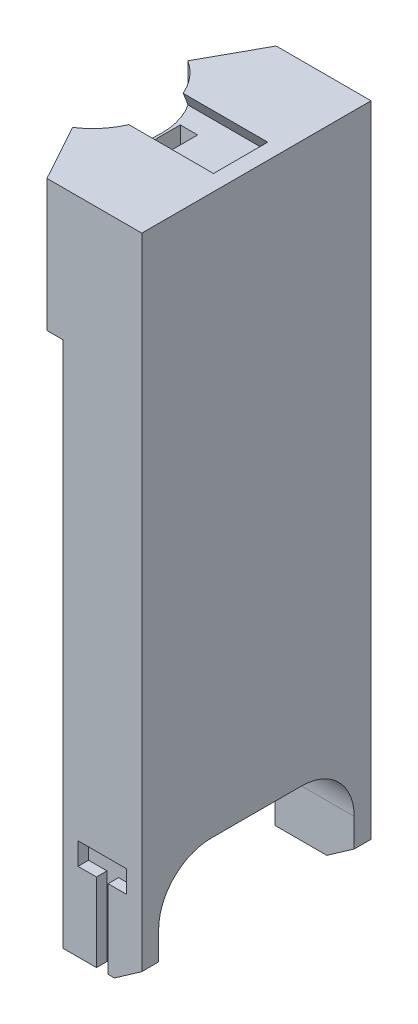
from build123d import *

# Parameters (mm, degrees)
SKETCH2_W               = 18
SKETCH2_H               = 43.5
BOSS_EXTRUDE1_DEPTH     = 25
CUT_EXTRUDE1_DEPTH      = 15
CUT_EXTRUDE1_DEPTH_BACK = 6.951267747
CUT_EXTRUDE2_START      = 0.4
CUT_EXTRUDE2_DEPTH      = 3.3
SKETCH5_W               = 15
SKETCH5_H               = 43.5
BOSS_EXTRUDE2_DEPTH     = 100
SKETCH6_W               = 2.2
SKETCH6_H               = 14.9
CUT_EXTRUDE3_DEPTH      = 2
CUT_EXTRUDE4_START      = -43.5
SKETCH6_3_W             = 2.2
SKETCH6_3_H             = 14.9
CUT_EXTRUDE4_DEPTH      = 2
CUT_EXTRUDE5_DEPTH      = 44.5
SKETCH8_W               = 37.1
SKETCH8_H               = 38
CUT_EXTRUDE6_DEPTH      = 16
FILLET1_R               = 10


with BuildPart() as part:
    # Sketch2 → Boss-Extrude1 (new body)
    with BuildSketch(Plane(origin=(0, 0, 0), x_dir=(1, 0, 0), z_dir=(0, 1, 0))):
        with BuildLine():
            Line((-9, 0), (-9, 21.75))
            Line((-9, 21.75), (-14.951267747, 10.950365309))
            ThreePointArc((-14.951267747, 10.950365309), (-10.583942354, 6.231534486), (-9, 0))
        make_face()
        with BuildLine():
            Line((-9, -21.75), (-9, 0))
            ThreePointArc((-9, 0), (-10.583942354, -6.231534486), (-14.951267747, -10.950365309))
            Line((-14.951267747, -10.950365309), (-9, -21.75))
        make_face()
        Rectangle(SKETCH2_W, SKETCH2_H)
    extrude(amount=BOSS_EXTRUDE1_DEPTH)

    # Sketch3 → Cut-Extrude1 (cut, two sides)
    with BuildSketch(Plane(origin=(-9, 0, 0), x_dir=(0, 0, -1), z_dir=(1, 0, 0))) as cut_extrude1_sk:
        Polygon((-5.15, 25), (5.15, 25), (7.15, 21.535898385), (-7.15, 21.535898385), align=None)
    extrude(amount=CUT_EXTRUDE1_DEPTH, mode=Mode.SUBTRACT)
    extrude(cut_extrude1_sk.sketch, amount=-CUT_EXTRUDE1_DEPTH_BACK, mode=Mode.SUBTRACT)

    # Sketch4 → Cut-Extrude2 (cut)
    with BuildSketch(Plane(origin=(-9, 0, 0), x_dir=(0, 0, -1), z_dir=(1, 0, 0)).offset(CUT_EXTRUDE2_START)):
        with BuildLine():
            Line((3.15, 29.404082691), (3.15, 4.535898385))
            ThreePointArc((3.15, 4.535898385), (0, 1.385898385), (-3.15, 4.535898385))
            Line((-3.15, 4.535898385), (-3.15, 29.404082691))
            ThreePointArc((-3.15, 29.404082691), (0, 32.554082691), (3.15, 29.404082691))
        make_face()
    extrude(amount=CUT_EXTRUDE2_DEPTH, mode=Mode.SUBTRACT)

    # Sketch5 → Boss-Extrude2 (add)
    with BuildSketch(Plane.XZ):
        with Locations((1.5, 0)):
            Rectangle(SKETCH5_W, SKETCH5_H)
    extrude(amount=BOSS_EXTRUDE2_DEPTH)

    # Sketch6 → Cut-Extrude3 (cut)
    with BuildSketch(Plane.XY.offset(21.75)):
        Polygon((-3.1, -85.1), (0.4, -85.1), (2.6, -85.1), (6.1, -85.1), (6.1, -80.9), (-3.1, -80.9), align=None)
        with Locations((1.5, -92.55)):
            Rectangle(SKETCH6_W, SKETCH6_H)
    extrude(amount=-CUT_EXTRUDE3_DEPTH, mode=Mode.SUBTRACT)

    # Sketch6_3 → Cut-Extrude4 (cut)
    with BuildSketch(Plane.XY.offset(21.75).offset(CUT_EXTRUDE4_START)):
        Polygon((-3.1, -85.1), (0.4, -85.1), (2.6, -85.1), (6.1, -85.1), (6.1, -80.9), (-3.1, -80.9), align=None)
        with Locations((1.5, -92.55)):
            Rectangle(SKETCH6_3_W, SKETCH6_3_H)
    extrude(amount=CUT_EXTRUDE4_DEPTH, mode=Mode.SUBTRACT)

    # Sketch7 → Cut-Extrude5 (cut, through all)
    with BuildSketch(Plane.XY.offset(21.75)):
        Polygon((9, -96.358920801), (3.8, -100), (9, -100), align=None)
    extrude(amount=-CUT_EXTRUDE5_DEPTH, mode=Mode.SUBTRACT)

    # Sketch8 → Cut-Extrude6 (cut, through all)
    with BuildSketch(Plane.ZY.offset(6)):
        with Locations((0, -100)):
            Rectangle(SKETCH8_W, SKETCH8_H)
    extrude(amount=-CUT_EXTRUDE6_DEPTH, mode=Mode.SUBTRACT)

    # Fillet1
    fillet1_edges = [part.edges().sort_by_distance(p)[0] for p in [
        (1.5, -81, 18.55),
        (1.5, -81, -18.55),
    ]]
    fillet(fillet1_edges, radius=FILLET1_R)


solid = part.part
